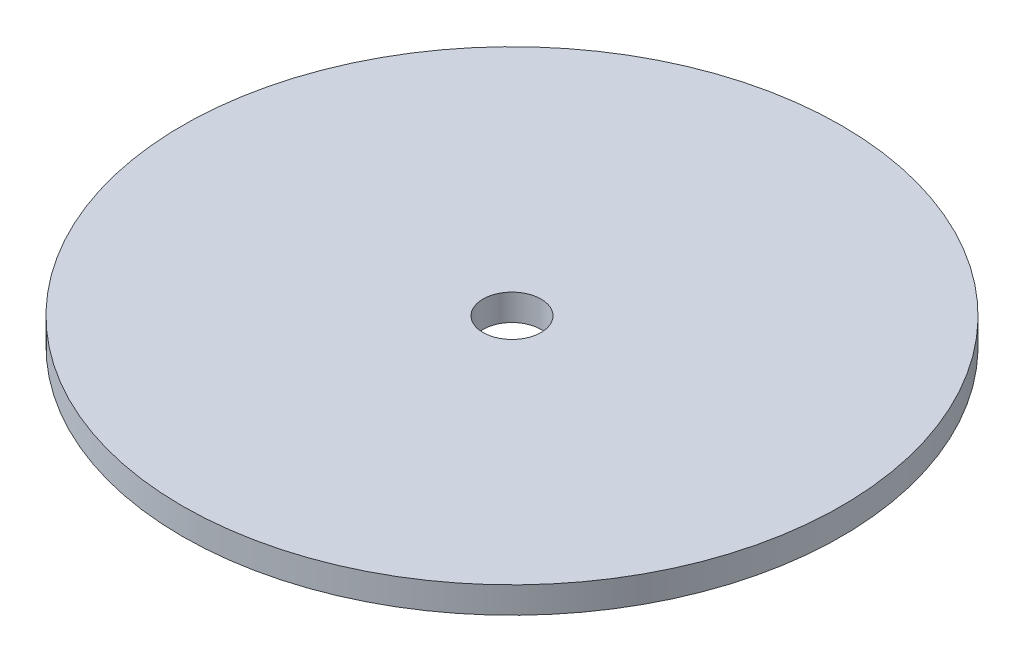
from build123d import *

# Parameters (mm, degrees)
SKETCH1_R           = 37.5
BOSS_EXTRUDE1_DEPTH = 3
SKETCH2_R           = 3.302
CUT_EXTRUDE1_DEPTH  = 4


with BuildPart() as part:
    # Sketch1 → Boss-Extrude1 (new body)
    with BuildSketch(Plane(origin=(0, 0, 0), x_dir=(1, 0, 0), z_dir=(0, 1, 0))):
        Circle(SKETCH1_R)
    extrude(amount=BOSS_EXTRUDE1_DEPTH)

    # Sketch2 → Cut-Extrude1 (cut, through all)
    with BuildSketch(Plane(origin=(0, 3, 0), x_dir=(1, 0, 0), z_dir=(0, 1, 0))):
        Circle(SKETCH2_R)
    extrude(amount=-CUT_EXTRUDE1_DEPTH, mode=Mode.SUBTRACT)


solid = part.part
